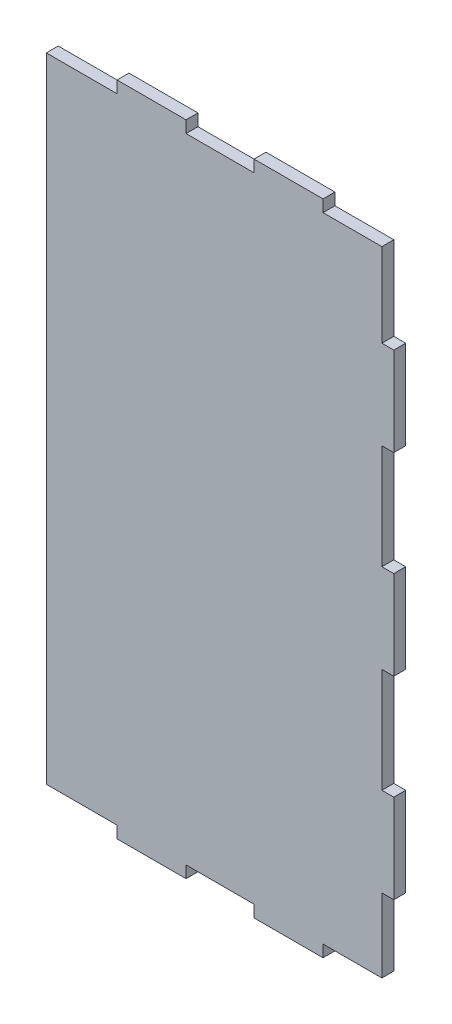
from build123d import *

# Parameters (mm, degrees)
BOSS_EXTRUDE1_DEPTH = 12


with BuildPart() as part:
    # Sketch1 → Boss-Extrude1 (new body)
    with BuildSketch(Plane.XY):
        Polygon((71.25, 0), (140.75, 0), (140.75, -12), (209.25, -12), (209.25, 0), (278.75, 0), (278.75, -12), (338, -12), (338, -96.25), (350, -96.25), (350, -185.75), (338, -185.75), (338, -291.25), (350, -291.25), (350, -380.75), (338, -380.75), (338, -486.25), (350, -486.25), (350, -575.75), (338, -575.75), (338, -650), (278.75, -650), (278.75, -662), (209.25, -662), (209.25, -650), (140.75, -650), (140.75, -662), (71.25, -662), (71.25, -650), (0, -650), (0, -12), (71.25, -12), align=None)
    extrude(amount=BOSS_EXTRUDE1_DEPTH)


solid = part.part
